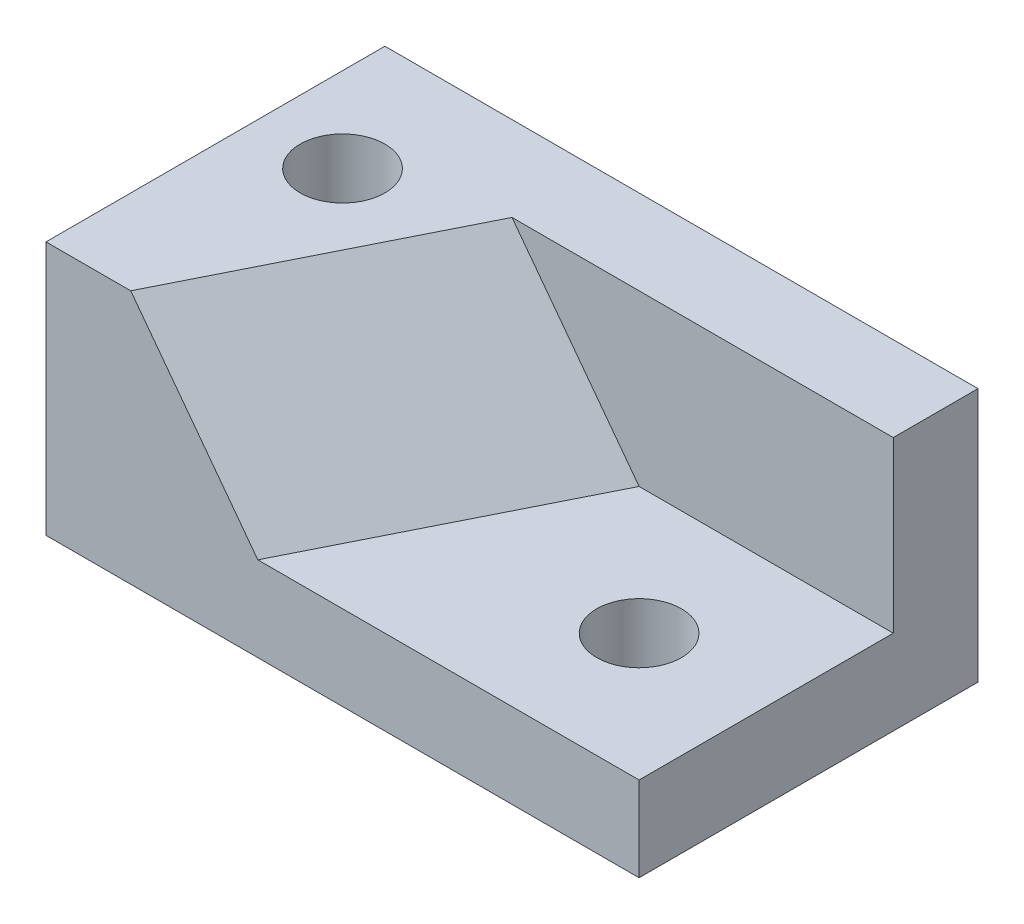
from build123d import *

# Parameters (mm, degrees)
SKETCH1_W           = 70
SKETCH1_H           = 40
BOSS_EXTRUDE1_DEPTH = 30
SKETCH2_W           = 30
SKETCH2_H           = 20
CUT_EXTRUDE1_DEPTH  = 30
CUT_EXTRUDE2_DEPTH  = 36
CUT_EXTRUDE3_DEPTH  = 49
CUT_EXTRUDE5_DEPTH  = 21
SKETCH11_R          = 5
CUT_EXTRUDE6_DEPTH  = 11
SKETCH12_R          = 5
CUT_EXTRUDE7_DEPTH  = 31


with BuildPart() as part:
    # Sketch1 → Boss-Extrude1 (new body)
    with BuildSketch(Plane(origin=(0, 0, 0), x_dir=(1, 0, 0), z_dir=(0, 1, 0))):
        with Locations((35, 20)):
            Rectangle(SKETCH1_W, SKETCH1_H)
    extrude(amount=BOSS_EXTRUDE1_DEPTH)

    # Sketch2 → Cut-Extrude1 (cut)
    with BuildSketch(Plane.XY):
        with Locations((55, 20)):
            Rectangle(SKETCH2_W, SKETCH2_H)
    extrude(amount=-CUT_EXTRUDE1_DEPTH, mode=Mode.SUBTRACT)

    # Sketch8 → Cut-Extrude2 (cut)
    with BuildSketch(Plane(origin=(17.931034483, 13.448275862, 8.965517241), x_dir=(0.297112541, 0.222834406, -0.928476691), z_dir=(0.742781353, 0.557086015, 0.371390676))):
        Polygon((9.656157585, 18), (9.656157585, -7), (41.967146428, -16), (41.967146428, 9), align=None)
    extrude(amount=CUT_EXTRUDE2_DEPTH, mode=Mode.SUBTRACT)

    # Sketch9 → Cut-Extrude3 (cut)
    with BuildSketch(Plane.XY.offset(-30)):
        Polygon((25, 30), (40, 10), (40, 30), align=None)
    extrude(amount=CUT_EXTRUDE3_DEPTH, mode=Mode.SUBTRACT)

    # Sketch10 → Cut-Extrude5 (cut)
    with BuildSketch(Plane(origin=(0, 10, 0), x_dir=(1, 0, 0), z_dir=(0, 1, 0))):
        Polygon((25, 0), (40, 0), (40, 30), align=None)
    extrude(amount=CUT_EXTRUDE5_DEPTH, mode=Mode.SUBTRACT)

    # Sketch11 → Cut-Extrude6 (cut, through all)
    with BuildSketch(Plane(origin=(0, 10, 0), x_dir=(1, 0, 0), z_dir=(0, 1, 0))):
        with Locations((55, 15)):
            Circle(SKETCH11_R)
    extrude(amount=-CUT_EXTRUDE6_DEPTH, mode=Mode.SUBTRACT)

    # Sketch12 → Cut-Extrude7 (cut, through all)
    with BuildSketch(Plane(origin=(0, 30, 0), x_dir=(1, 0, 0), z_dir=(0, 1, 0))):
        with Locations((10, 25)):
            Circle(SKETCH12_R)
    extrude(amount=-CUT_EXTRUDE7_DEPTH, mode=Mode.SUBTRACT)


solid = part.part
